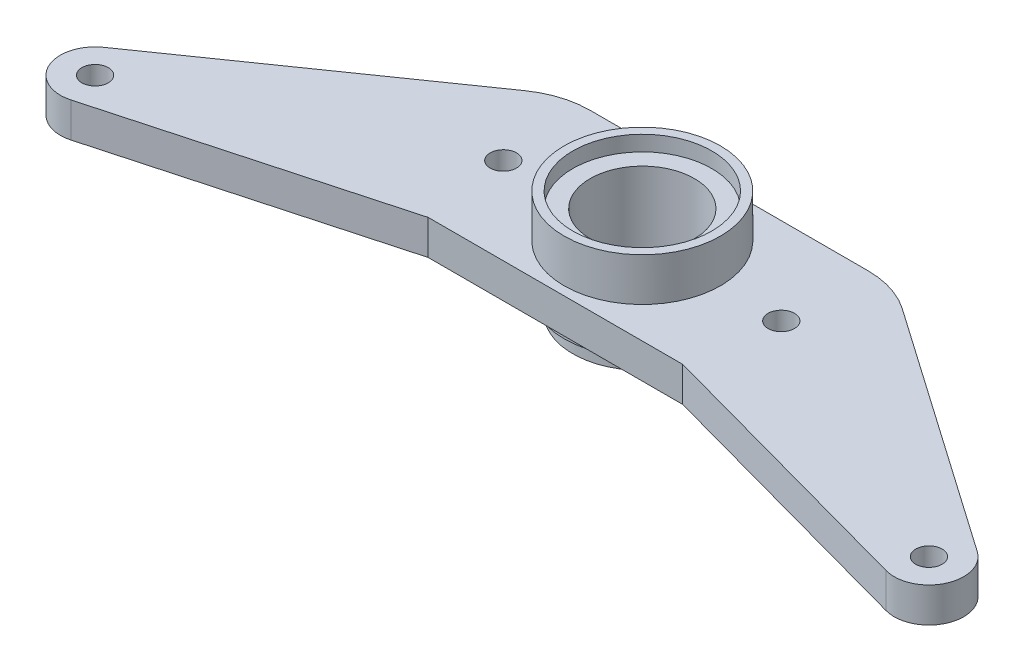
from build123d import *

# Parameters (mm, degrees)
BOSS_EXTRUDE1_DEPTH    = 6.35
BOSS_EXTRUDE2_START    = -14.224
SKETCH2_R              = 14.2875
BOSS_EXTRUDE2_DEPTH    = 19.431
HOLE1_D                = 19.05
HOLE1_DEPTH            = 19.05
HOLE1_CBORE_D          = 25.4
HOLE1_CBORE_DEPTH      = 2.794
F_10_32_TAPPED_HOLE1_D = 4.826
SKETCH7_R              = 14.2875
SKETCH7_R_2            = 12.7
CUT_EXTRUDE1_DEPTH     = 3.175


with BuildPart() as part:
    # Sketch1 → Boss-Extrude1 (new body)
    with BuildSketch(Plane(origin=(0, 0, 0), x_dir=(1, 0, 0), z_dir=(0, 1, 0))):
        with BuildLine():
            Line((79.832170731, -18.603869107), (34.480426828, 13.021577233))
            ThreePointArc((34.480426828, 13.021577233), (30.159101093, 15.14485331), (25.4, 15.875))
            Line((25.4, 15.875), (-25.4, 15.875))
            ThreePointArc((-25.4, 15.875), (-30.159101093, 15.14485331), (-34.480426828, 13.021577233))
            Line((-34.480426828, 13.021577233), (-79.832170731, -18.603869107))
            ThreePointArc((-79.832170731, -18.603869107), (-81.949664243, -26.507655114), (-74.520111094, -29.936262999))
            Line((-74.520111094, -29.936262999), (-23.262053626, -15.875))
            Line((-23.262053626, -15.875), (23.262053626, -15.875))
            Line((23.262053626, -15.875), (74.520111094, -29.936262999))
            ThreePointArc((74.520111094, -29.936262999), (81.949664243, -26.507655114), (79.832170731, -18.603869107))
        make_face()
    extrude(amount=BOSS_EXTRUDE1_DEPTH)

    # Sketch2 → Boss-Extrude2 (add)
    with BuildSketch(Plane.XZ.offset(BOSS_EXTRUDE2_START)):
        Circle(SKETCH2_R)
    extrude(amount=BOSS_EXTRUDE2_DEPTH)

    # Hole1
    with Locations(Plane(origin=(0, 14.224, 0), x_dir=(1, 0, 0), z_dir=(0, 1, 0))):
        with Locations((0, 0)):
            CounterBoreHole(HOLE1_D / 2, HOLE1_CBORE_D / 2, HOLE1_CBORE_DEPTH, depth=HOLE1_DEPTH)

    # #10-32 Tapped Hole1 (through all)
    with Locations(Plane(origin=(0, 6.35, 0), x_dir=(1, 0, 0), z_dir=(0, 1, 0))):
        with Locations((-25.4, 0), (25.4, 0), (-76.2, -23.8125), (76.2, -23.8125)):
            Hole(F_10_32_TAPPED_HOLE1_D / 2)

    # Sketch7 → Cut-Extrude1 (cut)
    with BuildSketch(Plane.XZ.offset(5.207)):
        Circle(SKETCH7_R)
        Circle(SKETCH7_R_2, mode=Mode.SUBTRACT)
    extrude(amount=-CUT_EXTRUDE1_DEPTH, mode=Mode.SUBTRACT)


solid = part.part
